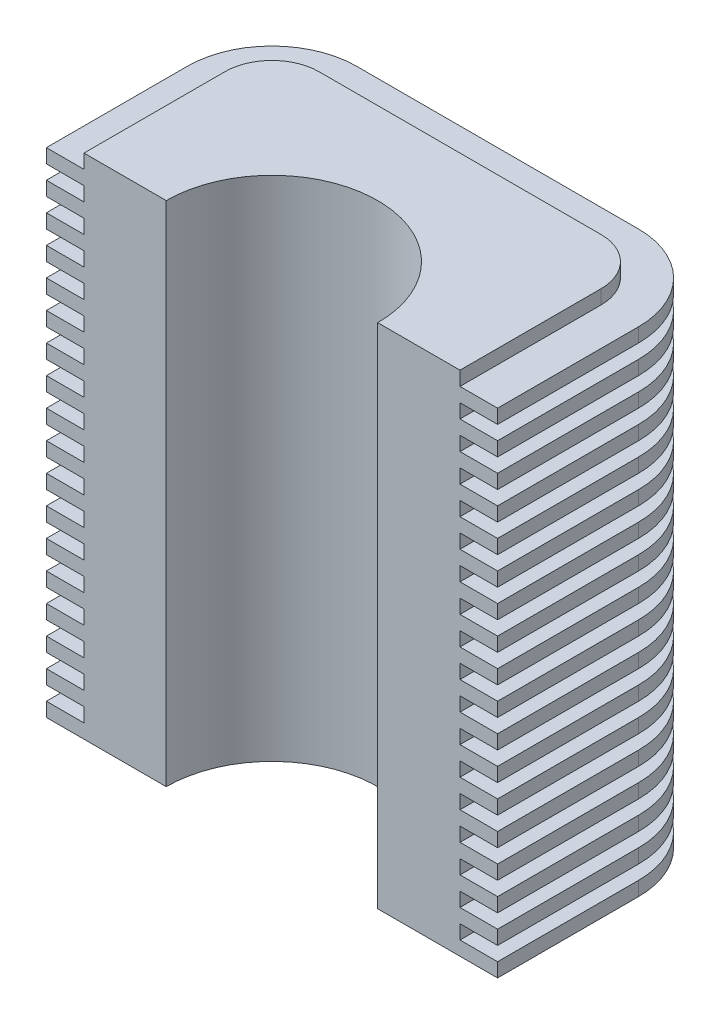
from build123d import *

# Parameters (mm, degrees)
DODANIE_WYCI_GNI_CIE1_DEPTH = 108
ZAOKR_GLENIE1_R             = 10
DODANIE_WYCI_GNI_CIE2_DEPTH = 3
SZYK_LINIOWY1_COUNT         = 18
SZYK_LINIOWY1_PITCH         = 6


with BuildPart() as part:
    # Szkic1 → Dodanie-wyciągnięcie1 (new body)
    with BuildSketch(Plane(origin=(0, 0, 0), x_dir=(1, 0, 0), z_dir=(0, 1, 0))):
        with BuildLine():
            Line((0, 0), (0, 40))
            Line((0, 40), (80, 40))
            Line((80, 40), (80, 0))
            Line((80, 0), (62.5, 0))
            ThreePointArc((62.5, 0), (40, 22.5), (17.5, 0))
            Line((17.5, 0), (0, 0))
        make_face()
    extrude(amount=DODANIE_WYCI_GNI_CIE1_DEPTH)

    # Zaokrąglenie1
    zaokr_glenie1_edges = [part.edges().sort_by_distance(p)[0] for p in [
        (0, 54, -40),
        (80, 54, -40),
    ]]
    fillet(zaokr_glenie1_edges, radius=ZAOKR_GLENIE1_R)

    # Szkic2 → Dodanie-wyciągnięcie2 (add)
    with BuildSketch(Plane.XZ):
        with BuildLine():
            Line((80, 0), (80, -30))
            ThreePointArc((80, -30), (77.071067812, -37.071067812), (70, -40))
            Line((70, -40), (10, -40))
            ThreePointArc((10, -40), (2.928932188, -37.071067812), (0, -30))
            Line((0, -30), (0, 0))
            Line((0, 0), (-8, 0))
            Line((-8, 0), (-8, -30))
            ThreePointArc((-8, -30), (-2.727922061, -42.727922061), (10, -48))
            Line((10, -48), (70, -48))
            ThreePointArc((70, -48), (82.727922061, -42.727922061), (88, -30))
            Line((88, -30), (88, 0))
            Line((88, 0), (80, 0))
        make_face()
    dodanie_wyci_gni_cie2 = extrude(amount=-DODANIE_WYCI_GNI_CIE2_DEPTH)

    # Szyk liniowy1: Dodanie-wyciągnięcie2 ×18
    with Locations(*[(0, i * SZYK_LINIOWY1_PITCH, 0) for i in range(1, SZYK_LINIOWY1_COUNT)]):
        add(dodanie_wyci_gni_cie2)


solid = part.part
